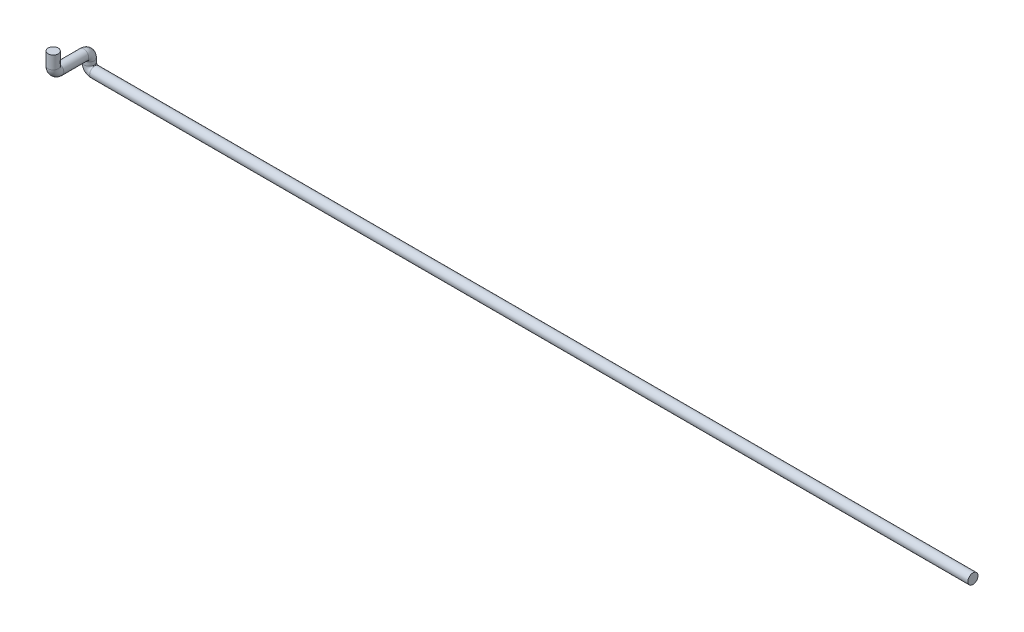
from build123d import *

# Parameters (mm, degrees)
CROQUIS1_R = 13.7


with BuildPart() as part:
    # Barrer1: sweep along a curve in space
    with BuildLine() as barrer1_path:
        Line((0, 0, 0), (-2374, 0, 0))
        ThreePointArc((-2374, 0, 0), (-2384.606601718, 4.393398282, 0), (-2389, 15, 0))
        Line((-2389, 15, 0), (-2389, 25, 0))
        ThreePointArc((-2389, 25, 0), (-2389, 35.606601718, 4.393398282), (-2389, 40, 15))
        Line((-2389, 40, 15), (-2389, 40, 82.5))
        ThreePointArc((-2389, 40, 82.5), (-2389, 44.393398282, 93.106601718), (-2389, 55, 97.5))
        Line((-2389, 55, 97.5), (-2389, 90, 97.5))
    # Croquis1 → Barrer1 (sweep)
    with BuildSketch(Plane(origin=(0, 0, 0), x_dir=(0, 0, -1), z_dir=(1, 0, 0))):
        Circle(CROQUIS1_R)
    sweep(path=barrer1_path.line)


solid = part.part
